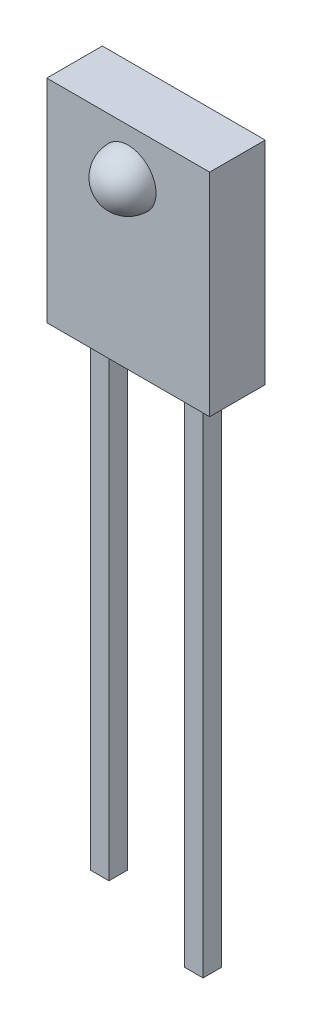
from build123d import *

# Parameters (mm, degrees)
SKETCH1_W           = 4.3942
SKETCH1_H           = 5.715
BOSS_EXTRUDE1_DEPTH = 0.7493
SKETCH4_W           = 0.5
SKETCH4_H           = 12.7
SKETCH4_H_2         = 13.7
BOSS_EXTRUDE2_DEPTH = 0.25


with BuildPart() as part:
    # Sketch1 → Boss-Extrude1 (new body, symmetric)
    with BuildSketch(Plane.XY):
        Rectangle(SKETCH1_W, SKETCH1_H)
    extrude(amount=BOSS_EXTRUDE1_DEPTH, both=True)

    # Sketch3 → Revolve1 (revolve)
    with BuildSketch(Plane(origin=(0, 0, 0), x_dir=(0, 0, -1), z_dir=(1, 0, 0))):
        with BuildLine():
            Line((-1.4993, 1.6375), (-0.7493, 1.6375))
            Line((-0.7493, 1.6375), (-0.7493, 2.3875))
            ThreePointArc((-0.7493, 2.3875), (-1.279630086, 2.167830086), (-1.4993, 1.6375))
        make_face()
    revolve(axis=Axis((0, 1.6375, 2.078989668), (0, 0, -1)))

    # Sketch4 → Boss-Extrude2 (add, symmetric)
    with BuildSketch(Plane.XY):
        with Locations((-1.27, -9.2075)):
            Rectangle(SKETCH4_W, SKETCH4_H)
        with Locations((1.27, -9.7075)):
            Rectangle(SKETCH4_W, SKETCH4_H_2)
    extrude(amount=BOSS_EXTRUDE2_DEPTH, both=True)


solid = part.part
